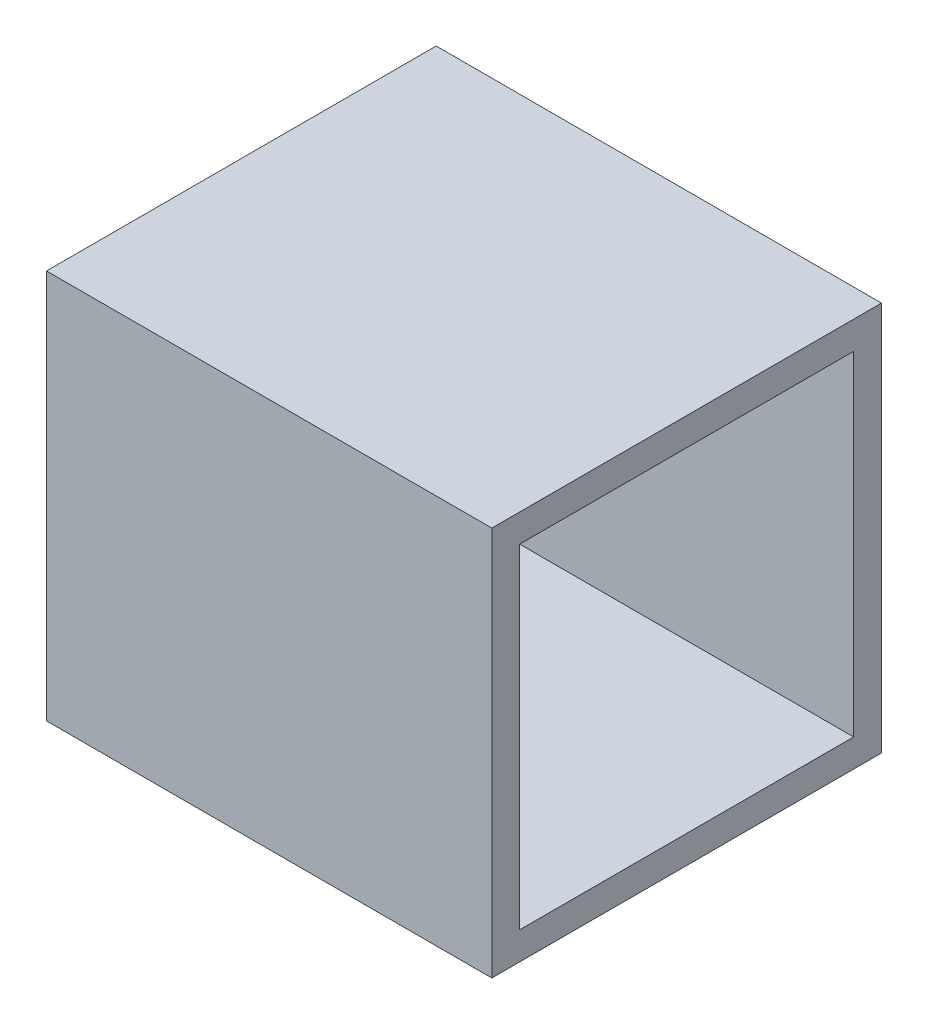
from build123d import *

# Parameters (mm, degrees)
SKETCH1_W               = 0.8
SKETCH1_H               = 0.7
BOSS_EXTRUDE1_DEPTH     = 0.7
SKETCH2_W               = 0.6
SKETCH2_H               = 0.6
CUT_EXTRUDE1_DEPTH      = 1
CUT_EXTRUDE1_DEPTH_BACK = 1.8


with BuildPart() as part:
    # Sketch1 → Boss-Extrude1 (new body)
    with BuildSketch(Plane(origin=(0, 0, 0), x_dir=(1, 0, 0), z_dir=(0, 1, 0))):
        with Locations((0.4, -0.35)):
            Rectangle(SKETCH1_W, SKETCH1_H)
    extrude(amount=BOSS_EXTRUDE1_DEPTH)

    # Sketch2 → Cut-Extrude1 (cut, two sides)
    with BuildSketch(Plane(origin=(0.8, 0, 0), x_dir=(0, 0, -1), z_dir=(1, 0, 0))) as cut_extrude1_sk:
        with Locations((-0.35, 0.35)):
            Rectangle(SKETCH2_W, SKETCH2_H)
    extrude(amount=CUT_EXTRUDE1_DEPTH, mode=Mode.SUBTRACT)
    extrude(cut_extrude1_sk.sketch, amount=-CUT_EXTRUDE1_DEPTH_BACK, mode=Mode.SUBTRACT)


solid = part.part
